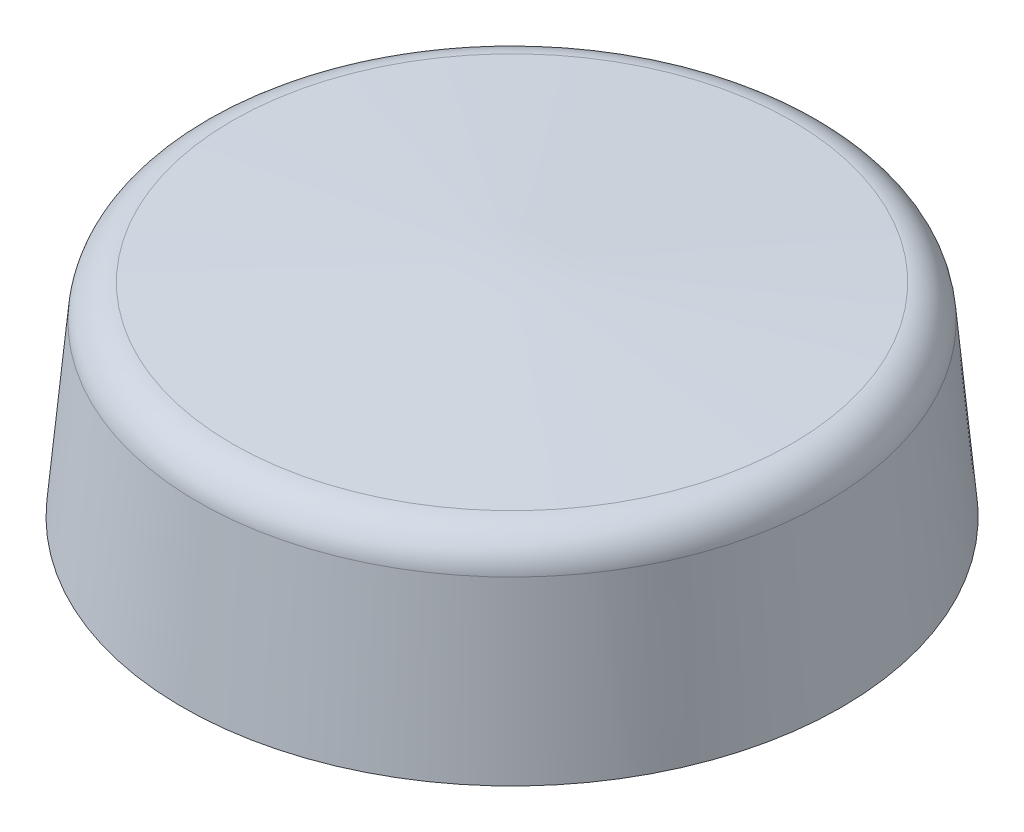
from build123d import *

# Parameters (mm, degrees)
FILLET1_R = 0.5


with BuildPart() as part:
    # Sketch1 → Revolve1 (revolve)
    with BuildSketch(Plane.XY):
        Polygon((4.5, 0), (0, 0), (0, 3), (4.25, 2.75), align=None)
    revolve(axis=Axis((0, -102.327395421, 0), (0, 1, 0)))

    # Fillet1
    fillet1_edges = [part.edges().sort_by_distance(p)[0] for p in [
        (-4.25, 2.75, 0),
    ]]
    fillet(fillet1_edges, radius=FILLET1_R)


solid = part.part
